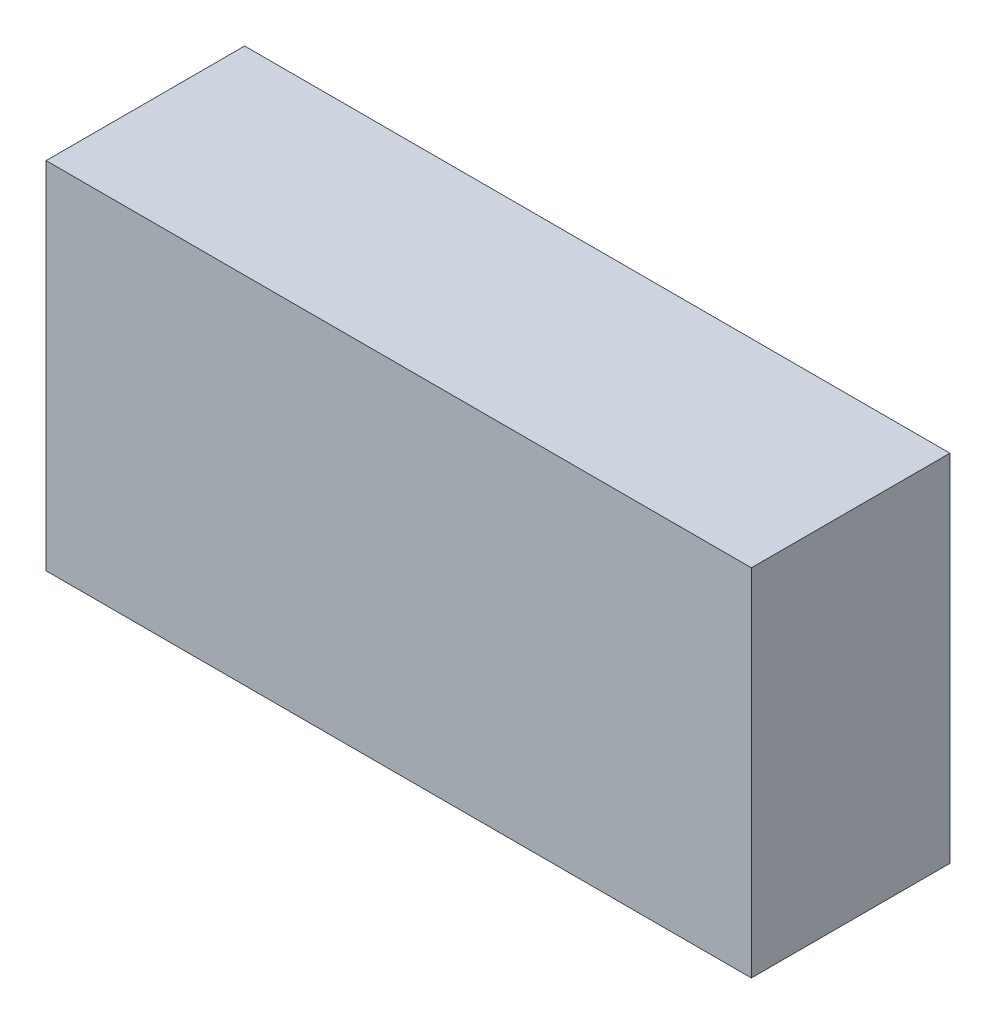
from build123d import *

# Parameters (mm, degrees)
SKETCH_1_W          = 135
SKETCH_1_H          = 38
EXTRUDE_312_DEPTH   = 68
SKETCH_2_W          = 39
SKETCH_2_H          = 15
CUT_EXTRUDE_1_DEPTH = 66
SKETCH_4_W          = 53
SKETCH_4_H          = 9.428155193
CUT_EXTRUDE_2_DEPTH = 66
SKETCH_6_W          = 53
SKETCH_6_H          = 10.153175229
CUT_EXTRUDE_3_DEPTH = 66
SKETCH_7_W          = 30.334064535
SKETCH_7_H          = 3
SKETCH_7_W_2        = 33.750062794
SKETCH_7_W_3        = 31.017264187
CUT_EXTRUDE_4_DEPTH = 66
SKETCH_11_W         = 28.831025302
SKETCH_11_H         = 3.4
SKETCH_11_W_2       = 31.973743699
SKETCH_11_H_2       = 1.4
SKETCH_11_W_3       = 29.240945093
CUT_EXTRUDE_6_DEPTH = 63
SKETCH_12_W         = 31.973743699
SKETCH_12_H         = 2
CUT_EXTRUDE_7_DEPTH = 63


with BuildPart() as part:
    # Эскиз1 → Extrude 312 (new body)
    with BuildSketch(Plane(origin=(0, 0, 0), x_dir=(1, 0, 0), z_dir=(0, 1, 0))):
        with Locations((67.5, 19)):
            Rectangle(SKETCH_1_W, SKETCH_1_H)
    extrude(amount=EXTRUDE_312_DEPTH)

    # Эскиз2 → Вырез-Вытянуть1 (cut)
    with BuildSketch(Plane.XZ):
        with Locations((21.5, -9.1)):
            Rectangle(SKETCH_2_W, SKETCH_2_H)
        with Locations((67.5, -9.1)):
            Rectangle(SKETCH_2_W, SKETCH_2_H)
        with Locations((113.5, -9.1)):
            Rectangle(SKETCH_2_W, SKETCH_2_H)
        with Locations((67.5, -27.1)):
            Rectangle(SKETCH_2_W, SKETCH_2_H)
        with Locations((113.5, -27.1)):
            Rectangle(SKETCH_2_W, SKETCH_2_H)
        with Locations((21.5, -27.1)):
            Rectangle(SKETCH_2_W, SKETCH_2_H)
    extrude(amount=-CUT_EXTRUDE_1_DEPTH, mode=Mode.SUBTRACT)

    # Эскиз4 → Вырез-Вытянуть2 (cut)
    with BuildSketch(Plane.XZ):
        with Locations((67.5, -10.503524842)):
            Rectangle(SKETCH_4_W, SKETCH_4_H)
    extrude(amount=-CUT_EXTRUDE_2_DEPTH, mode=Mode.SUBTRACT)

    # Эскиз6 → Вырез-Вытянуть3 (cut)
    with BuildSketch(Plane.XZ):
        with Locations((67.5, -28.288326327)):
            Rectangle(SKETCH_6_W, SKETCH_6_H)
    extrude(amount=-CUT_EXTRUDE_3_DEPTH, mode=Mode.SUBTRACT)

    # Эскиз7 → Вырез-Вытянуть4 (cut)
    with BuildSketch(Plane.XZ):
        with Locations((22.818742778, -18.1)):
            Rectangle(SKETCH_7_W, SKETCH_7_H)
        with Locations((67.158400174, -18.1)):
            Rectangle(SKETCH_7_W_2, SKETCH_7_H)
        with Locations((112.112937257, -18.1)):
            Rectangle(SKETCH_7_W_3, SKETCH_7_H)
    extrude(amount=-CUT_EXTRUDE_4_DEPTH, mode=Mode.SUBTRACT)

    # Эскиз11 → Вырез-Вытянуть6 (cut)
    with BuildSketch(Plane.XZ):
        with Locations((22.203863092, -36.3)):
            Rectangle(SKETCH_11_W, SKETCH_11_H)
        with Locations((67.36336007, -37.3)):
            Rectangle(SKETCH_11_W_2, SKETCH_11_H_2)
        with Locations((112.591177012, -36.3)):
            Rectangle(SKETCH_11_W_3, SKETCH_11_H)
    extrude(amount=-CUT_EXTRUDE_6_DEPTH, mode=Mode.SUBTRACT)

    # Эскиз12 → Вырез-Вытянуть7 (cut)
    with BuildSketch(Plane.XZ):
        with Locations((67.36336007, -35.6)):
            Rectangle(SKETCH_12_W, SKETCH_12_H)
    extrude(amount=-CUT_EXTRUDE_7_DEPTH, mode=Mode.SUBTRACT)


solid = part.part
